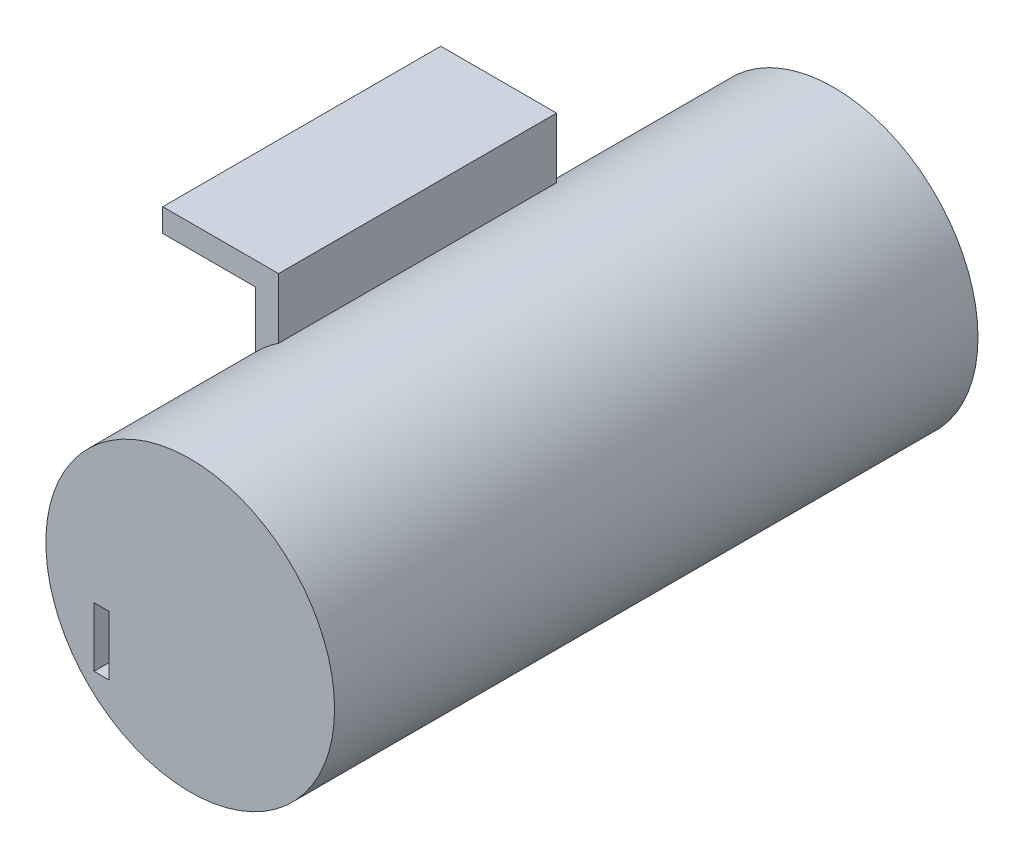
from build123d import *

# Parameters (mm, degrees)
SKETCH1_W                = 12.7
SKETCH1_H                = 3.175
SKETCH1_W_2              = 3.175
SKETCH1_H_2              = 11
BOSS_EXTRUDE1_DEPTH      = 38.1
SKETCH2_R                = 19.784587186
SKETCH2_R_2              = 18.4
BOSS_EXTRUDE2_DEPTH      = 27
BOSS_EXTRUDE2_DEPTH_BACK = 58
SKETCH3_R                = 19.784587186
BOSS_EXTRUDE3_DEPTH      = 3.175
SKETCH4_W                = 2.053355329
SKETCH4_H                = 8.144976138
CUT_EXTRUDE1_DEPTH       = 3.175


with BuildPart() as part:
    # Sketch1 → Boss-Extrude1 (new body)
    with BuildSketch(Plane.XY):
        with Locations((-16.162006615, 10.28820212)):
            Rectangle(SKETCH1_W, SKETCH1_H)
        with Locations((-8.224506615, 6.37570212)):
            Rectangle(SKETCH1_W_2, SKETCH1_H_2)
    extrude(amount=BOSS_EXTRUDE1_DEPTH)

    # Sketch2 → Boss-Extrude2 (add, two sides)
    with BuildSketch(Plane(origin=(0, 0, 0), x_dir=(-1, 0, 0), z_dir=(0, 0, -1))) as boss_extrude2_sk:
        with Locations((-4.329778131, -12.861954284)):
            Circle(SKETCH2_R)
        with Locations((-4.329778131, -12.861954284)):
            Circle(SKETCH2_R_2, mode=Mode.SUBTRACT)
    extrude(amount=BOSS_EXTRUDE2_DEPTH)
    extrude(boss_extrude2_sk.sketch, amount=-BOSS_EXTRUDE2_DEPTH_BACK)

    # Sketch3 → Boss-Extrude3 (add)
    with BuildSketch(Plane.XY.offset(58)):
        with Locations((4.329778131, -12.861954284)):
            Circle(SKETCH3_R)
    extrude(amount=BOSS_EXTRUDE3_DEPTH)

    # Sketch4 → Cut-Extrude1 (cut)
    with BuildSketch(Plane.XY.offset(61.175)):
        with Locations((-7.822913032, -20.823309264)):
            Rectangle(SKETCH4_W, SKETCH4_H)
    extrude(amount=-CUT_EXTRUDE1_DEPTH, mode=Mode.SUBTRACT)


solid = part.part
